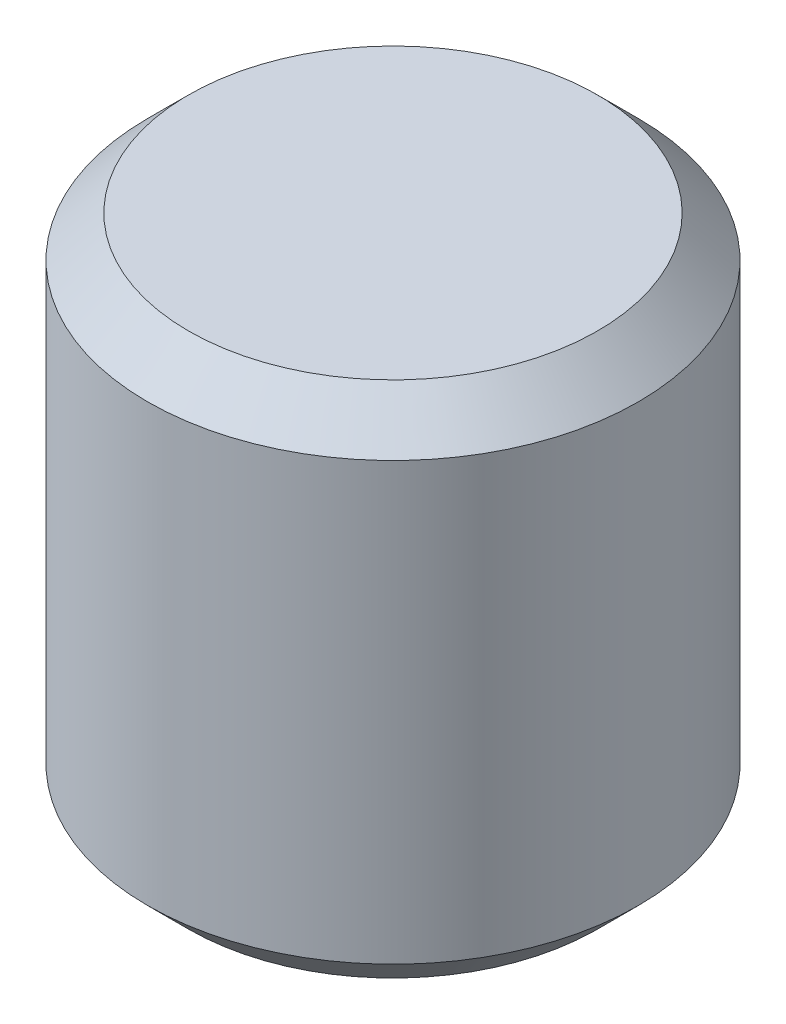
from build123d import *

# Parameters (mm, degrees)
SKETCH1_R           = 9
BOSS_EXTRUDE1_DEPTH = 19
CHAMFER1_SIZE       = 1.5


with BuildPart() as part:
    # Sketch1 → Boss-Extrude1 (new body)
    with BuildSketch(Plane(origin=(0, 0, 0), x_dir=(1, 0, 0), z_dir=(0, 1, 0))):
        with Locations(Location((0, 0, 0), (0, 0, 270))):  # turned: the seam where the file's is
            Circle(SKETCH1_R)
    extrude(amount=BOSS_EXTRUDE1_DEPTH)

    # Chamfer1
    chamfer1_edges = [part.edges().sort_by_distance(p)[0] for p in [
        (0, 0, -9),
        (0, 19, -9),
    ]]
    chamfer(chamfer1_edges, length=CHAMFER1_SIZE)


solid = part.part
